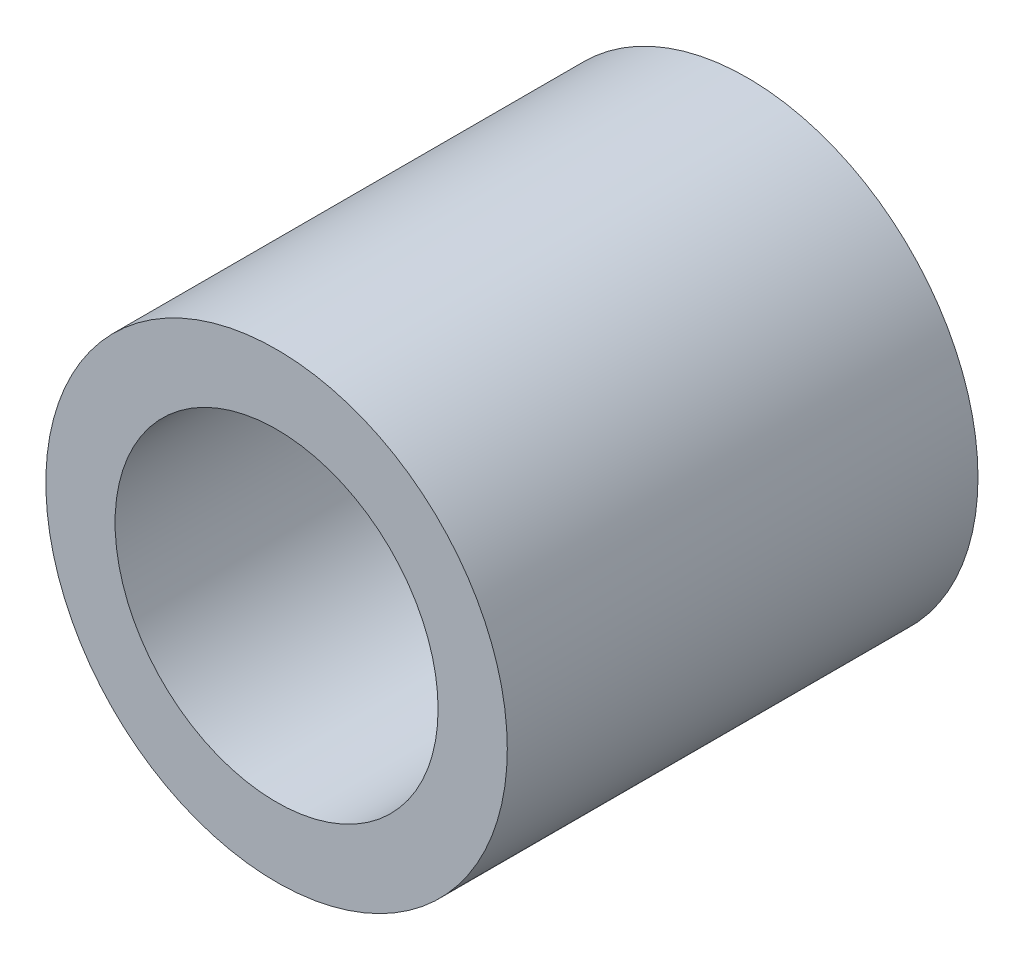
from build123d import *

# Parameters (mm, degrees)
SKETCH1_R           = 25
SKETCH1_R_2         = 17.5
BOSS_EXTRUDE1_DEPTH = 51


with BuildPart() as part:
    # Sketch1 → Boss-Extrude1 (new body)
    with BuildSketch(Plane.XY):
        Circle(SKETCH1_R)
        Circle(SKETCH1_R_2, mode=Mode.SUBTRACT)
    extrude(amount=BOSS_EXTRUDE1_DEPTH)


solid = part.part
